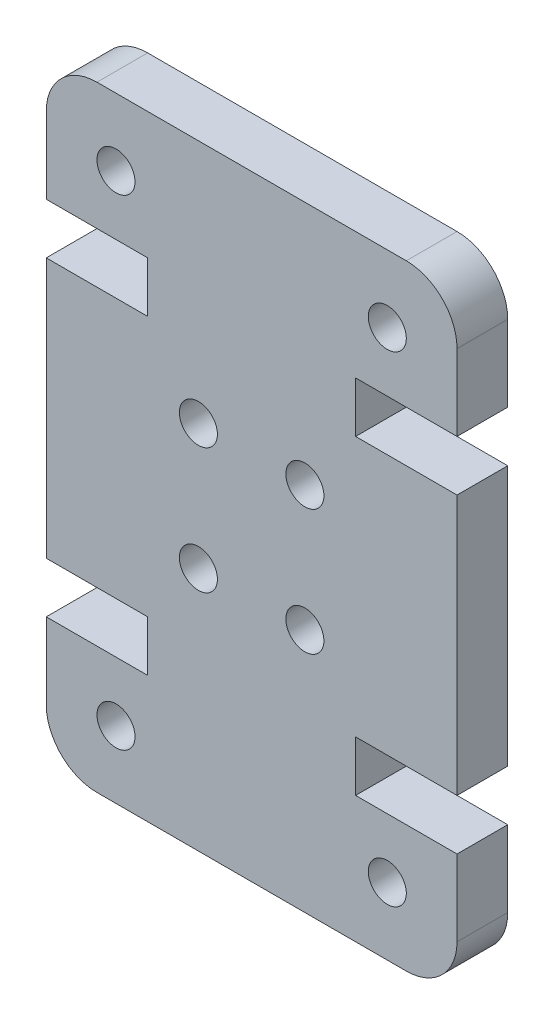
from build123d import *

# Parameters (mm, degrees)
SKETCH1_R           = 0.75
BOSS_EXTRUDE1_DEPTH = 2


with BuildPart() as part:
    # Sketch1 → Boss-Extrude1 (new body)
    with BuildSketch(Plane.XY):
        with BuildLine():
            Line((16.2, 17.26), (16.2, 7))
            Line((16.2, 7), (12.2, 7))
            Line((12.2, 7), (12.2, 5))
            Line((12.2, 5), (16.2, 5))
            Line((16.2, 5), (16.2, 2))
            ThreePointArc((16.2, 2), (15.614213562, 0.585786438), (14.2, 0))
            Line((14.2, 0), (2, 0))
            ThreePointArc((2, 0), (0.585786438, 0.585786438), (0, 2))
            Line((0, 2), (0, 5))
            Line((0, 5), (4, 5))
            Line((4, 5), (4, 7))
            Line((4, 7), (0, 7))
            Line((0, 7), (0, 17.26))
            Line((0, 17.26), (4, 17.26))
            Line((4, 17.26), (4, 19.26))
            Line((4, 19.26), (0, 19.26))
            Line((0, 19.26), (0, 22.26))
            ThreePointArc((0, 22.26), (0.585786438, 23.674213562), (2, 24.26))
            Line((2, 24.26), (14.2, 24.26))
            ThreePointArc((14.2, 24.26), (15.614213562, 23.674213562), (16.2, 22.26))
            Line((16.2, 22.26), (16.2, 19.26))
            Line((16.2, 19.26), (12.2, 19.26))
            Line((12.2, 19.26), (12.2, 17.26))
            Line((12.2, 17.26), (16.2, 17.26))
        make_face()
        with Locations((13.45, 2.653551169)):
            Circle(SKETCH1_R, mode=Mode.SUBTRACT)
        with Locations((10.2, 9.653551169)):
            Circle(SKETCH1_R, mode=Mode.SUBTRACT)
        with Locations((2.75, 21.606448831)):
            Circle(SKETCH1_R, mode=Mode.SUBTRACT)
        with Locations((6, 14.606448831)):
            Circle(SKETCH1_R, mode=Mode.SUBTRACT)
        with Locations((10.2, 14.606448831)):
            Circle(SKETCH1_R, mode=Mode.SUBTRACT)
        with Locations((13.45, 21.606448831)):
            Circle(SKETCH1_R, mode=Mode.SUBTRACT)
        with Locations((6, 9.653551169)):
            Circle(SKETCH1_R, mode=Mode.SUBTRACT)
        with Locations((2.75, 2.653551169)):
            Circle(SKETCH1_R, mode=Mode.SUBTRACT)
    extrude(amount=BOSS_EXTRUDE1_DEPTH)


solid = part.part
